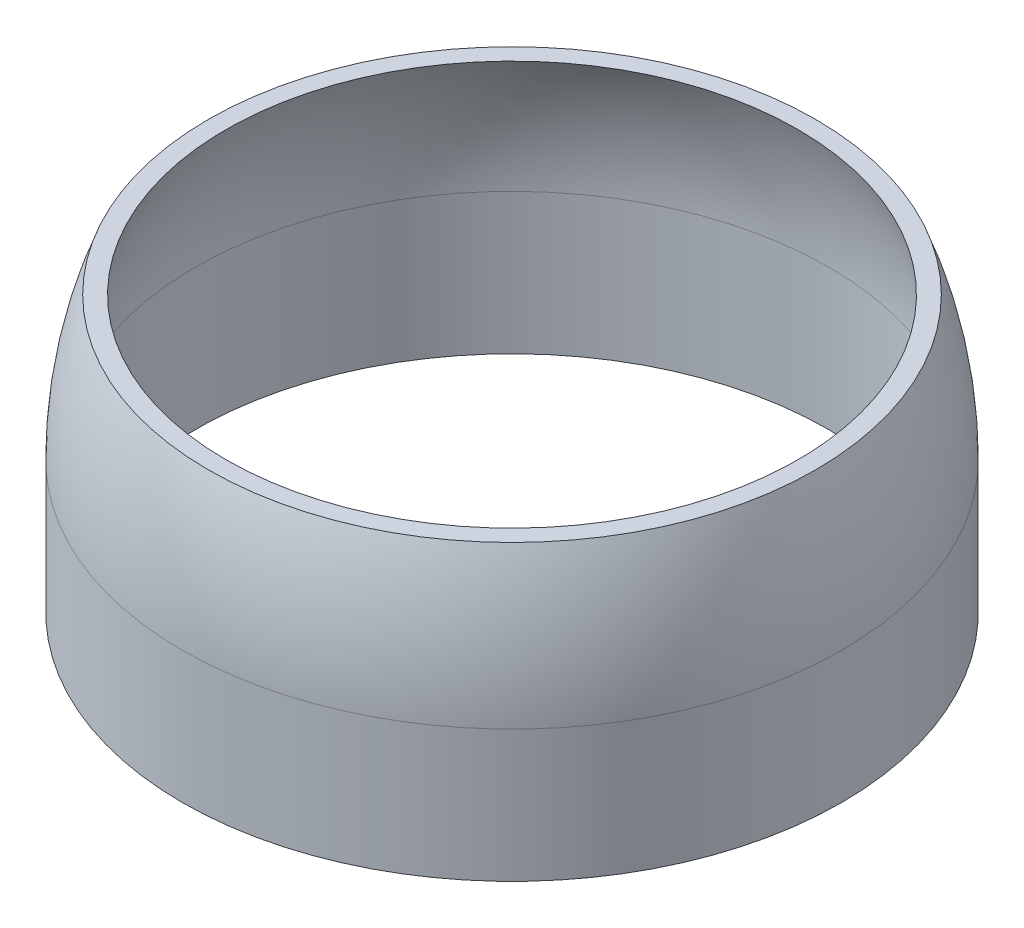
from build123d import *


with BuildPart() as part:
    # Sketch1 → Revolve1 (revolve)
    with BuildSketch(Plane.XY):
        with BuildLine():
            Line((-36, -30.5), (-37.5, -30.5))
            Line((-37.5, -30.5), (-37.5, -15.5))
            ThreePointArc((-37.5, -15.5), (-36.751331251, -7.22440118), (-34.529635305, 0.782477602))
            Line((-34.529635305, 0.782477602), (-32.529635305, 0.782477602))
            ThreePointArc((-32.529635305, 0.782477602), (-35.121503693, -6.664223829), (-36, -14.5))
            Line((-36, -14.5), (-36, -30.5))
        make_face()
    revolve(axis=Axis((0, 0, 0), (0, 1, 0)))


solid = part.part
